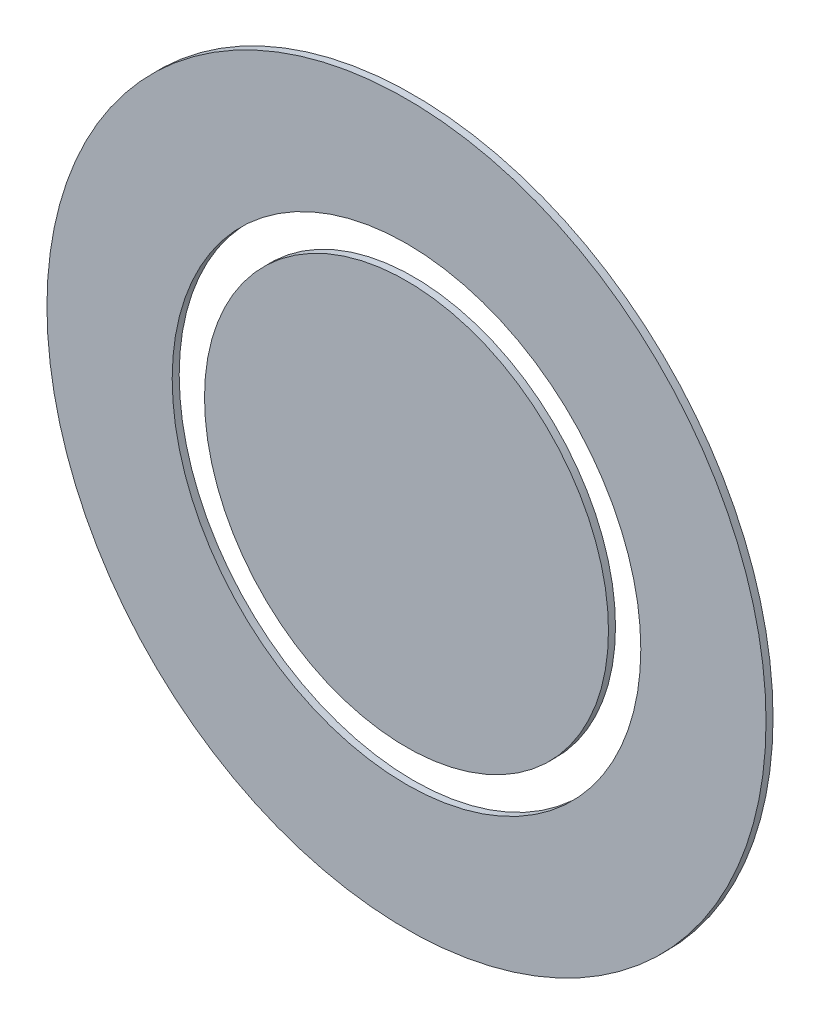
from build123d import *

# Parameters (mm, degrees)
SKETCH2_R           = 75
BOSS_EXTRUDE1_DEPTH = 2.6
SKETCH2_3_R         = 133.5
SKETCH2_3_R_2       = 87
BOSS_EXTRUDE2_DEPTH = 2.6


with BuildPart() as part:
    # Sketch2 → Boss-Extrude1 (new body)
    with BuildSketch(Plane.XY):
        Circle(SKETCH2_R)
    extrude(amount=BOSS_EXTRUDE1_DEPTH)


with BuildPart() as body_2:
    # Sketch2_3 → Boss-Extrude2 (new body)
    with BuildSketch(Plane.XY):
        Circle(SKETCH2_3_R)
        Circle(SKETCH2_3_R_2, mode=Mode.SUBTRACT)
    extrude(amount=BOSS_EXTRUDE2_DEPTH)


solid = Compound([part.part, body_2.part])
